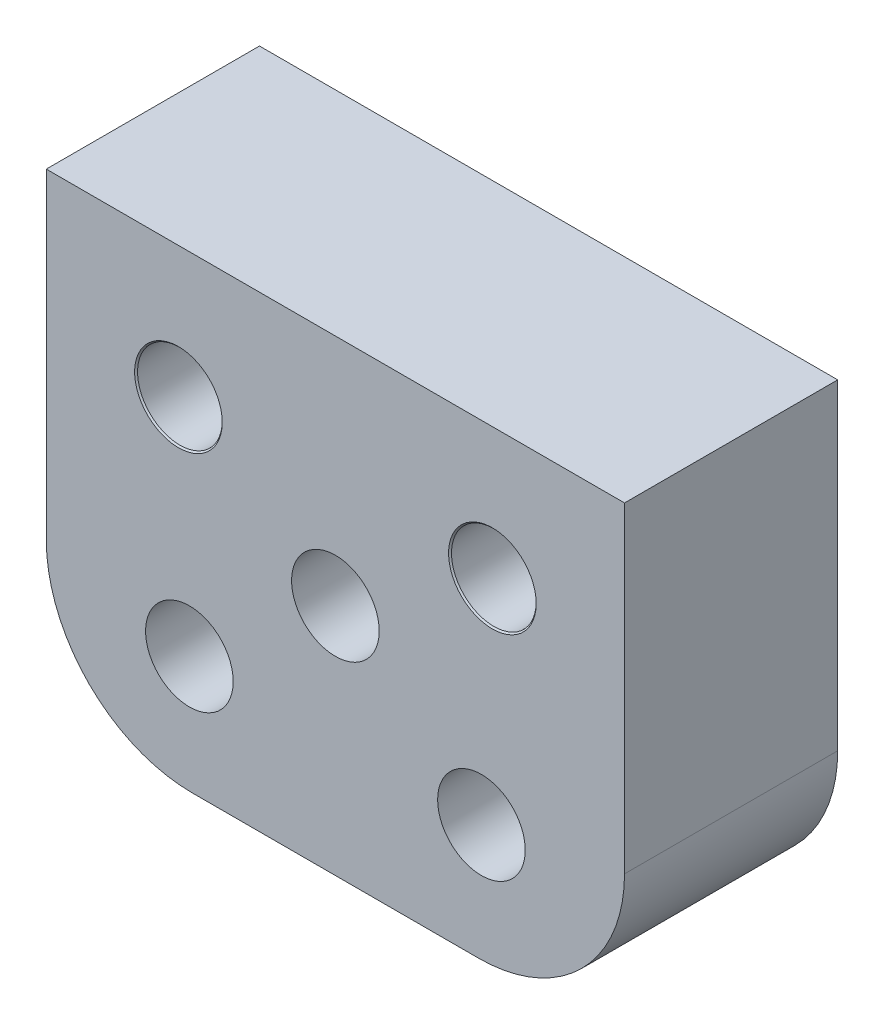
from build123d import *

# Parameters (mm, degrees)
SKETCH_1_R                   = 1.5
SKETCH_1_R_2                 = 1.25
EXTRUDE_1_DEPTH              = 7.3
HOLE_WIZARD_M2_51_AT_2_COUNT = 2
HOLE_WIZARD_M2_51_AT_2_PITCH = 10.75


with BuildPart() as part:
    # Эскиз1 → Бобышка-Вытянуть1 (new body)
    with BuildSketch(Plane.XY):
        with BuildLine():
            Line((5, 0), (14.8, 0))
            ThreePointArc((14.8, 0), (18.335533906, 1.464466094), (19.8, 5))
            Line((19.8, 5), (19.8, 16))
            Line((19.8, 16), (0, 16))
            Line((0, 16), (0, 5))
            ThreePointArc((0, 5), (1.464466094, 1.464466094), (5, 0))
        make_face()
        with Locations((9.9, 8)):
            Circle(SKETCH_1_R, mode=Mode.SUBTRACT)
        with Locations((4.525, 11.5)):
            Circle(SKETCH_1_R_2, mode=Mode.SUBTRACT)
        with Locations((4.9, 4)):
            Circle(SKETCH_1_R, mode=Mode.SUBTRACT)
        with Locations((14.9, 4)):
            Circle(SKETCH_1_R, mode=Mode.SUBTRACT)
        with Locations((15.275, 11.5)):
            Circle(SKETCH_1_R_2, mode=Mode.SUBTRACT)
    extrude(amount=-EXTRUDE_1_DEPTH)

    # Эскиз2 → Зенковка для  винта с плоской головкой M2.51 (revolve, cut)
    with BuildSketch(Plane(origin=(4.525, 11.5, 0), x_dir=(0, -1, 0), z_dir=(1, 0, 0))):
        Polygon((0, 0), (0, 7.3), (1.5, 7.3), (1.45, 7.25), (1.45, 0.05), (1.5, 0), align=None)
    hole_wizard_m2_51 = revolve(axis=Axis((4.525, 11.5, 6.35), (0, 0, -1)), mode=Mode.SUBTRACT)

    # Зенковка для  винта с плоской головкой M2.51 at 2: Зенковка для  винта с плоской головкой M2.51 ×2
    with Locations(*[(i * HOLE_WIZARD_M2_51_AT_2_PITCH, 0, 0) for i in range(1, HOLE_WIZARD_M2_51_AT_2_COUNT)]):
        add(hole_wizard_m2_51, mode=Mode.SUBTRACT)


solid = part.part
